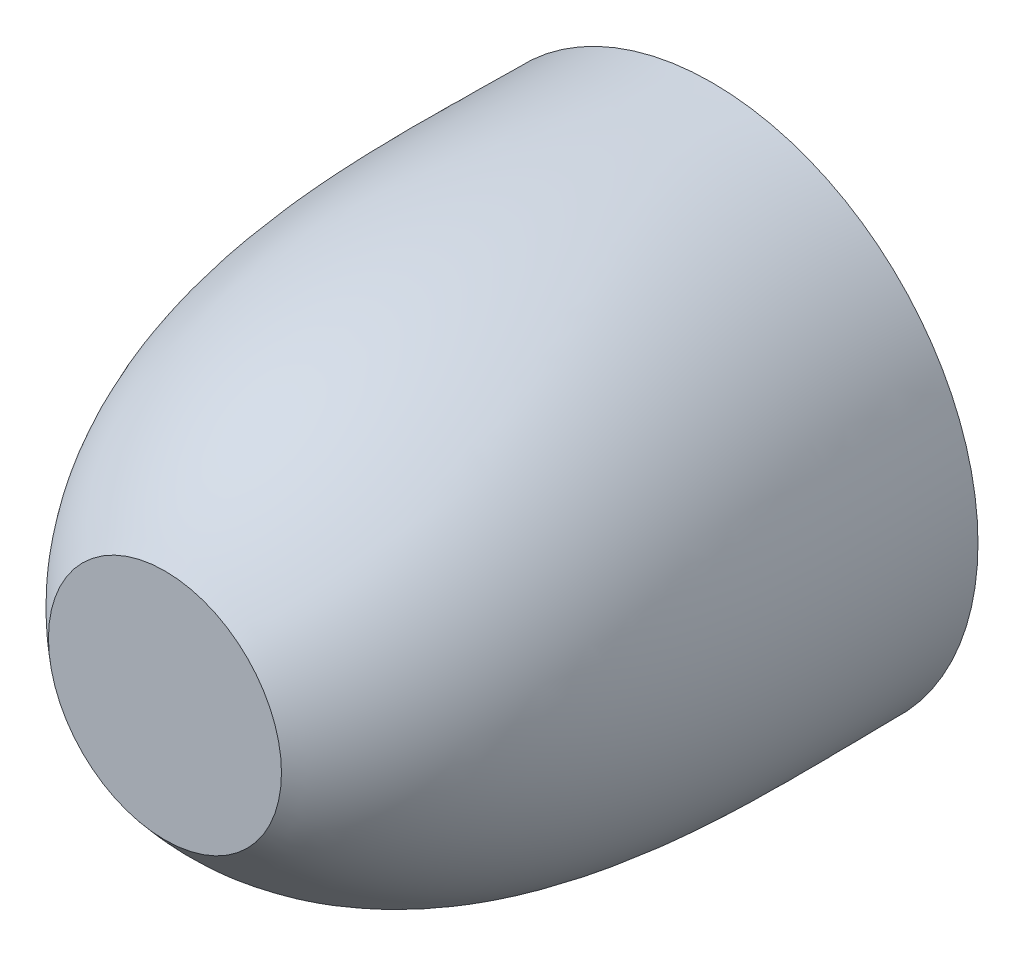
from build123d import *

# Parameters (mm, degrees)
BOSS_EXTRUDE1_START = -5
SKETCH2_R           = 5
SKETCH2_R_2         = 1.5
BOSS_EXTRUDE1_DEPTH = 2


with BuildPart() as part:
    # Sketch1 → shell (revolve)
    with BuildSketch(Plane(origin=(0, 0, 0), x_dir=(1, 0, 0), z_dir=(0, 1, 0))):
        with BuildLine():
            Line((11.5, -4), (0, -4))
            Line((0, -4), (0, 0))
            Line((0, 0), (10, 0))
            add(Edge.make_bspline(
                [(10, 0), (24.034381635, 12.248187609), (22.25, 34.257055754), (22.25, 50)],
                knots=[0, 0, 0, 0, 1, 1, 1, 1], degree=3))
            Line((22.25, 50), (26.25, 50))
            add(Edge.make_bspline(
                [(11.5, -4), (11.725173343, -3.803485082), (12.067418801, -3.504749737), (12.505804305, -3.122287819), (13.003995722, -2.686986315), (13.631035477, -2.110599487), (14.586618128, -1.177906899), (15.718513744, 0.032272543), (17.388046624, 2.04442819), (19.221282106, 4.692166419), (21.648969692, 9.149559888), (23.823527306, 15.033546425), (25.361055027, 22.339489226), (26.116247645, 29.693496956), (26.311712181, 35.706717236), (26.329483565, 40.350371596), (26.302675507, 43.724921754), (26.27083444, 46.419765101), (26.253607546, 48.500738482), (26.25, 49.496517954), (26.25, 50)],
                knots=[-0.026842104, -0.026842104, -0.026842104, -0.026842104, -0.010797696, -0.002775492, 0.005246712, 0.02129112, 0.037335528, 0.069424343, 0.101513159, 0.165690791, 0.229868422, 0.358223685, 0.486578948, 0.614934211, 0.743289474, 0.807467106, 0.871644737, 0.935822369, 0.967911184, 1, 1, 1, 1], degree=3))
        make_face()
    revolve(axis=Axis((0, 0, 0), (0, 0, -1)))


with BuildPart() as body_2:
    # Sketch2 → Boss-Extrude1 (new body)
    with BuildSketch(Plane(origin=(0, 0, -50), x_dir=(-1, 0, 0), z_dir=(0, 0, -1)).offset(BOSS_EXTRUDE1_START)):
        with BuildLine():
            Line((14.643314066, -16.752189503), (4.3116044, -2.531811111))
            ThreePointArc((4.3116044, -2.531811111), (2.938926261, -4.045084972), (1.075536422, -4.88295212))
            Line((1.075536422, -4.88295212), (11.407246089, -19.103330512))
            ThreePointArc((11.407246089, -19.103330512), (13.078221864, -18.000628125), (14.643314066, -16.752189503))
        make_face()
        Circle(SKETCH2_R)
        Circle(SKETCH2_R_2, mode=Mode.SUBTRACT)
        with BuildLine():
            ThreePointArc((-1.075536422, -4.88295212), (-2.938926261, -4.045084972), (-4.3116044, -2.531811111))
            Line((-4.3116044, -2.531811111), (-14.643314066, -16.752189503))
            ThreePointArc((-14.643314066, -16.752189503), (-13.078221864, -18.000628125), (-11.407246089, -19.103330512))
            Line((-11.407246089, -19.103330512), (-1.075536422, -4.88295212))
        make_face()
        with BuildLine():
            ThreePointArc((-4.976322465, -0.486019265), (-4.755282581, 1.545084972), (-3.740254487, 3.3182068))
            Line((-3.740254487, 3.3182068), (-20.45731189, 8.749908013))
            ThreePointArc((-20.45731189, 8.749908013), (-21.161007488, 6.875628125), (-21.693379867, 4.945681948))
            Line((-21.693379867, 4.945681948), (-4.976322465, -0.486019265))
        make_face()
        with BuildLine():
            ThreePointArc((-2, 4.582575695), (0, 5), (2, 4.582575695))
            Line((2, 4.582575695), (2, 22.159930054))
            ThreePointArc((2, 22.159930054), (0, 22.25), (-2, 22.159930054))
            Line((-2, 22.159930054), (-2, 4.582575695))
        make_face()
        with BuildLine():
            Line((20.45731189, 8.749908013), (3.740254487, 3.3182068))
            ThreePointArc((3.740254487, 3.3182068), (4.67446641, 1.774644692), (5, 0))
            ThreePointArc((5, 0), (4.994077108, -0.243297838), (4.976322465, -0.486019265))
            Line((4.976322465, -0.486019265), (21.693379867, 4.945681948))
            ThreePointArc((21.693379867, 4.945681948), (21.161007488, 6.875628125), (20.45731189, 8.749908013))
        make_face()
    extrude(amount=-BOSS_EXTRUDE1_DEPTH)


solid = Compound([part.part, body_2.part])
